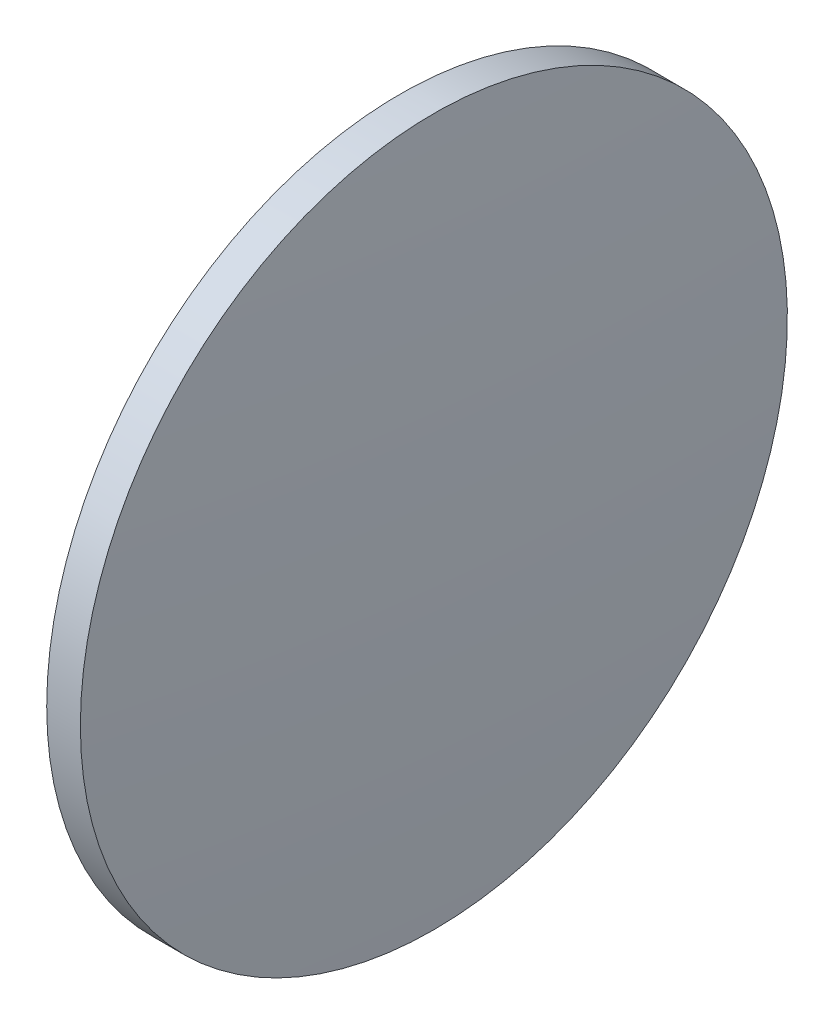
from build123d import *


with BuildPart() as part:
    # 草图1 → 旋转1 (revolve)
    with BuildSketch(Plane.XY, mode=Mode.PRIVATE) as revolve_1_sk:
        with BuildLine():
            Line((226.893301001, 130.518581457), (226.893301001, 162.018581457))
            Line((226.893301001, 162.018581457), (229.893301001, 162.018581457))
            ThreePointArc((229.893301001, 162.018581457), (230.613245299, 146.275894045), (230.853301001, 130.518581457))
            Line((230.853301001, 130.518581457), (226.893301001, 130.518581457))
        make_face()
    revolve(revolve_1_sk.sketch.rotate(Axis((218.123666737, 130.518581457, 0), (1, 0, 0)), 180), axis=Axis((218.123666737, 130.518581457, 0), (1, 0, 0)))  # turned: the seam where the file's is


solid = part.part
